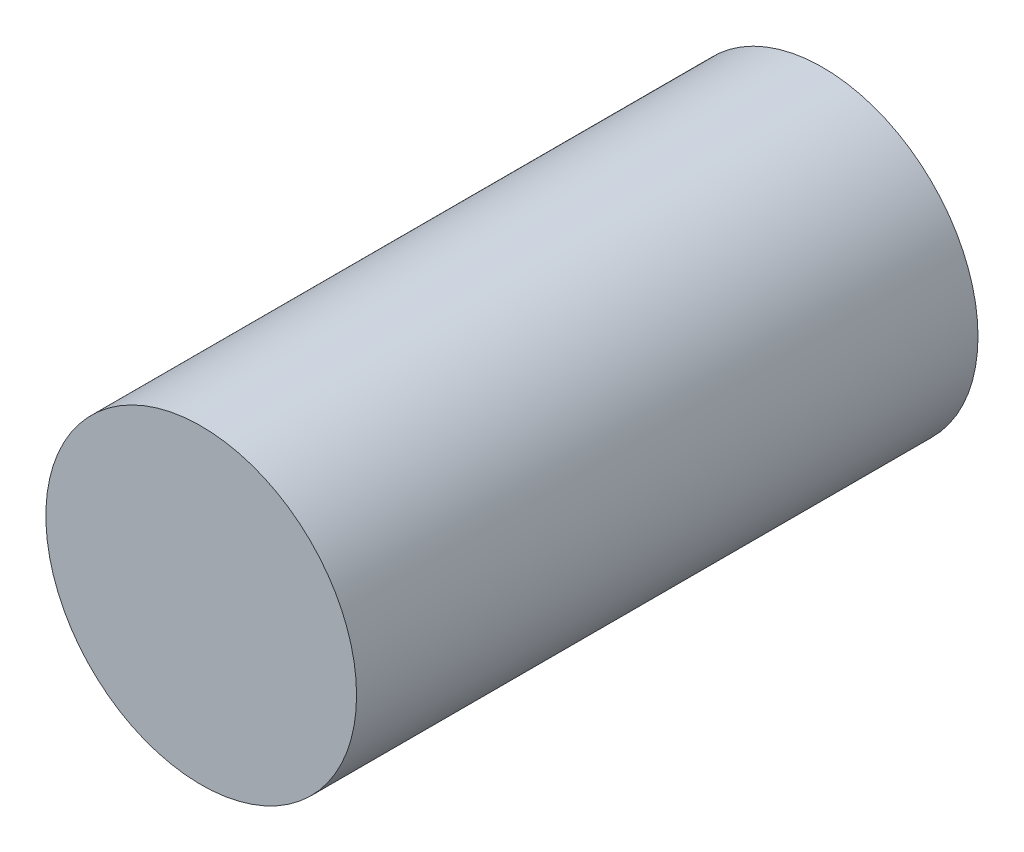
from build123d import *

# Parameters (mm, degrees)
SKETCH2_R           = 5
BOSS_EXTRUDE1_DEPTH = 20


with BuildPart() as part:
    # Sketch2 → Boss-Extrude1 (new body)
    with BuildSketch(Plane.XY):
        Circle(SKETCH2_R)
    extrude(amount=BOSS_EXTRUDE1_DEPTH)


solid = part.part
